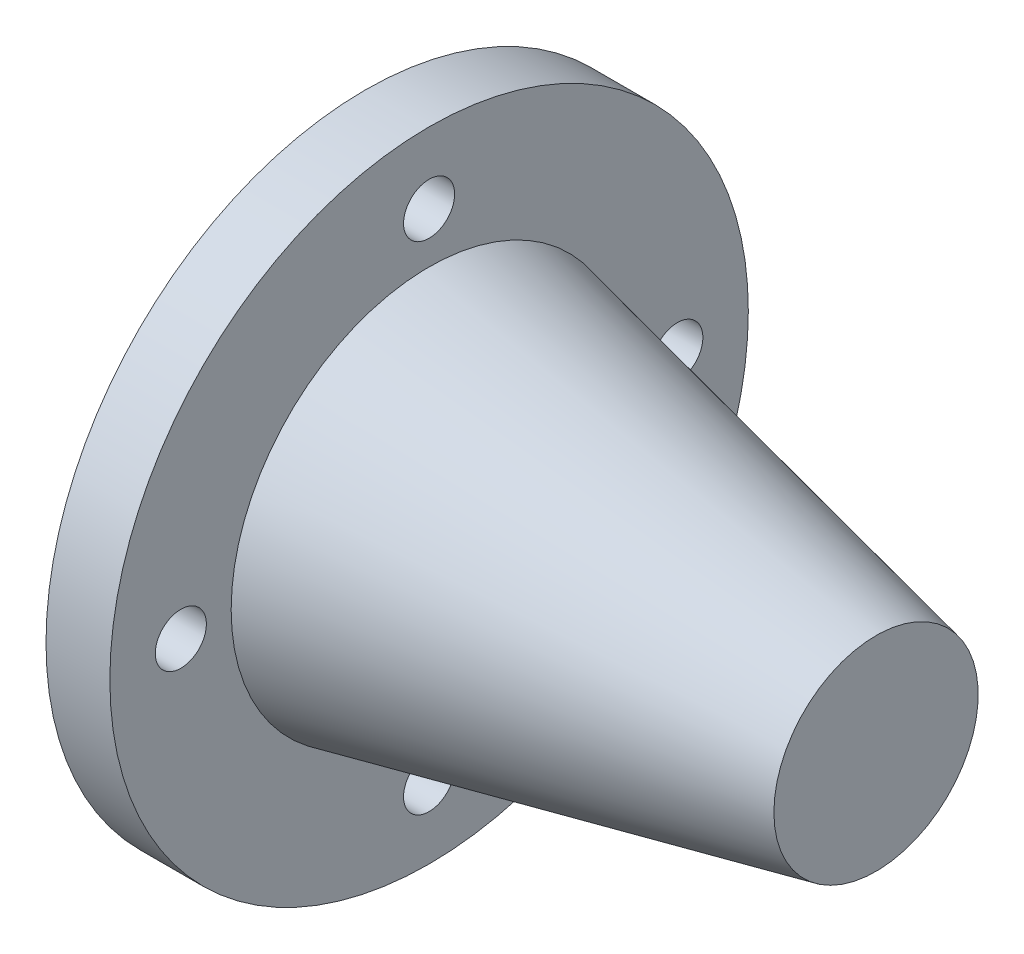
from build123d import *

# Parameters (mm, degrees)
F_4_0_4_DURCHMESSER_BOHRUNG1_D     = 4
F_4_0_4_DURCHMESSER_BOHRUNG1_DEPTH = 5.001
KREISMUSTER1_COUNT                 = 4


with BuildPart() as part:
    # Skizze1 → Rotation1 (revolve)
    with BuildSketch(Plane.XY):
        Polygon((0, 12.75), (3, 12.75), (3, 9.75), (23, 7.5), (38, 0), (40, 0), (40, 8), (5, 15.5), (5, 25), (0, 25), align=None)
    revolve(axis=Axis((-34.842488806, 0, 0), (1, 0, 0)))

    # Ø4.0 (4) Durchmesser Bohrung1
    with Locations(Plane.ZY):
        with Locations((-19.44, 0)):
            f_4_0_4_durchmesser_bohrung1 = Hole(F_4_0_4_DURCHMESSER_BOHRUNG1_D / 2, depth=F_4_0_4_DURCHMESSER_BOHRUNG1_DEPTH)

    # Kreismuster1: Ø4.0 (4) Durchmesser Bohrung1 ×4 about axis
    kreismuster1_axis = Axis((0, 0, 0), (1, 0, 0))
    for i in range(1, KREISMUSTER1_COUNT):
        add(f_4_0_4_durchmesser_bohrung1.rotate(kreismuster1_axis, i * 360 / KREISMUSTER1_COUNT), mode=Mode.SUBTRACT)


solid = part.part
